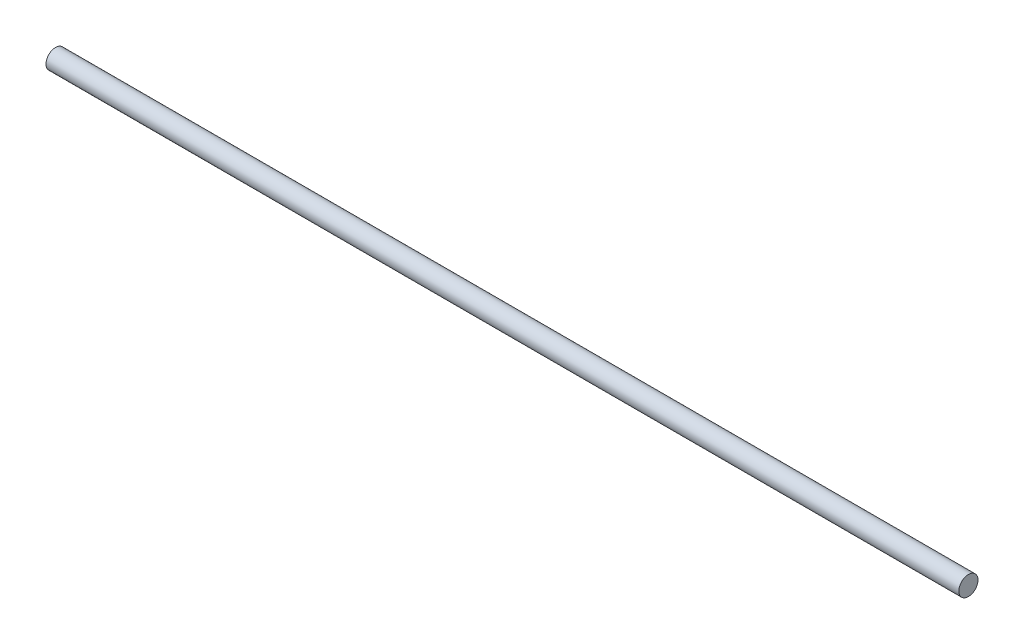
from build123d import *

# Parameters (mm, degrees)
SKETCH1_R           = 1.5875
BOSS_EXTRUDE1_DEPTH = 75.565


with BuildPart() as part:
    # Sketch1 → Boss-Extrude1 (new body, symmetric)
    with BuildSketch(Plane(origin=(0, 0, 0), x_dir=(0, 0, -1), z_dir=(1, 0, 0))):
        Circle(SKETCH1_R)
    extrude(amount=BOSS_EXTRUDE1_DEPTH, both=True)


solid = part.part
